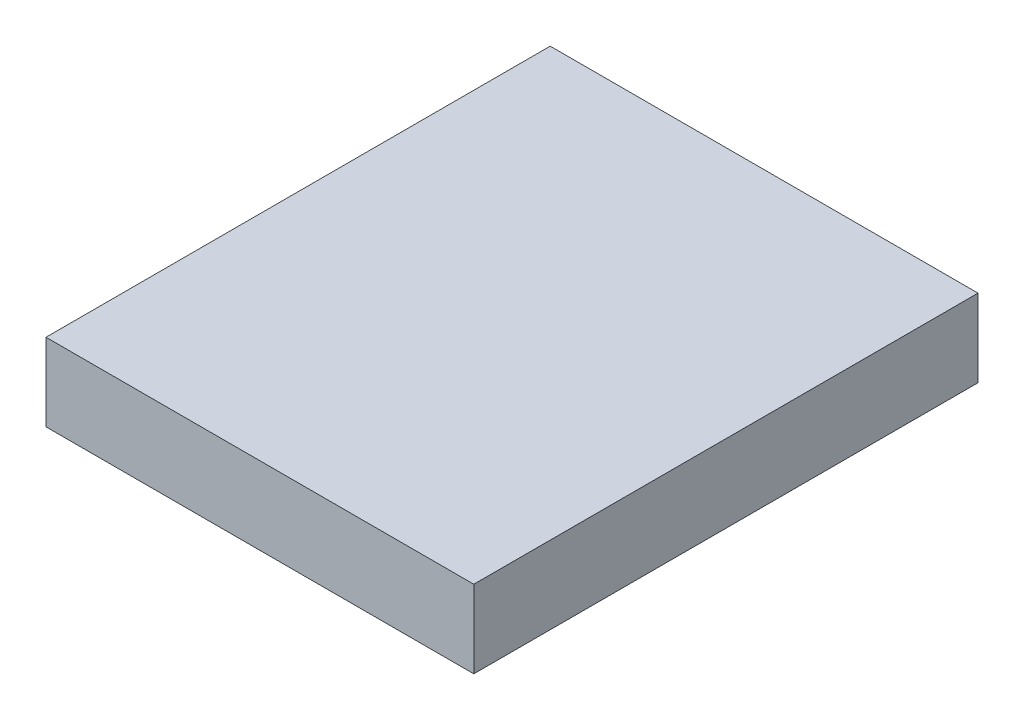
from build123d import *

# Parameters (mm, degrees)
SKETCH1_W           = 70
SKETCH1_H           = 82.5
BOSS_EXTRUDE1_DEPTH = 12.7


with BuildPart() as part:
    # Sketch1 → Boss-Extrude1 (new body)
    with BuildSketch(Plane(origin=(0, 0, 0), x_dir=(1, 0, 0), z_dir=(0, 1, 0))):
        with Locations((35, 41.25)):
            Rectangle(SKETCH1_W, SKETCH1_H)
    extrude(amount=BOSS_EXTRUDE1_DEPTH)


solid = part.part
